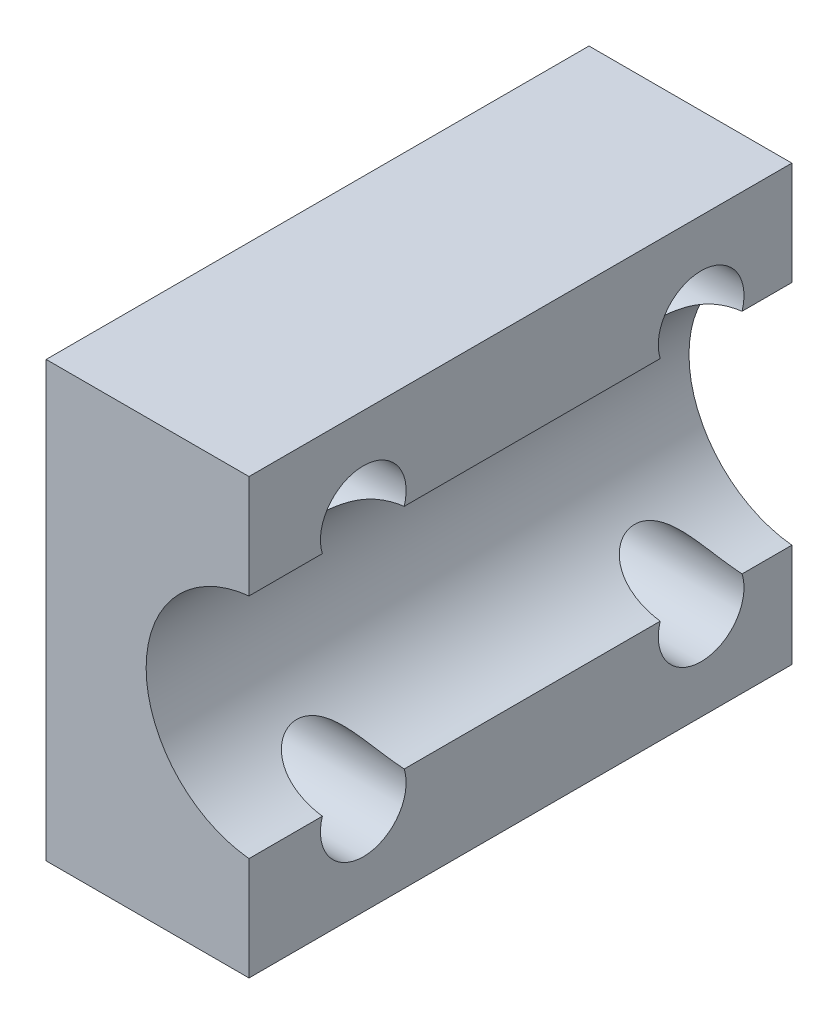
from build123d import *

# Parameters (mm, degrees)
EXTRUDE1_DEPTH = 19
SKETCH2_R      = 1.5
EXTRUDE5_DEPTH = 8.5
SKETCH3_W      = 0.4
SKETCH3_H      = 15.2
EXTRUDE6_DEPTH = 20.0000001


with BuildPart() as part:
    # Sketch1 → Extrude1 (new body)
    with BuildSketch(Plane.XY):
        with BuildLine():
            Line((0, 4), (0, 7.6))
            Line((0, 7.6), (-7.5, 7.6))
            Line((-7.5, 7.6), (-7.5, -7.6))
            Line((-7.5, -7.6), (0, -7.6))
            Line((0, -7.6), (0, -4))
            ThreePointArc((0, -4), (-4, 0), (0, 4))
        make_face()
    extrude(amount=EXTRUDE1_DEPTH)

    # Sketch2 → Extrude5 (cut, through all)
    with BuildSketch(Plane(origin=(-7.5, 0, 0), x_dir=(0, 0, -1), z_dir=(1, 0, 0))):
        with Locations((-3.175, 4.425)):
            Circle(SKETCH2_R)
        with Locations((-15, 4.425)):
            Circle(SKETCH2_R)
        with Locations((-15, -4.425)):
            Circle(SKETCH2_R)
        with Locations((-3.175, -4.425)):
            Circle(SKETCH2_R)
    extrude(amount=EXTRUDE5_DEPTH, mode=Mode.SUBTRACT)

    # Sketch3 → Extrude6 (cut, through all)
    with BuildSketch(Plane.XY.offset(19)):
        with Locations((-0.2, 0)):
            Rectangle(SKETCH3_W, SKETCH3_H)
    extrude(amount=-EXTRUDE6_DEPTH, mode=Mode.SUBTRACT)


solid = part.part
